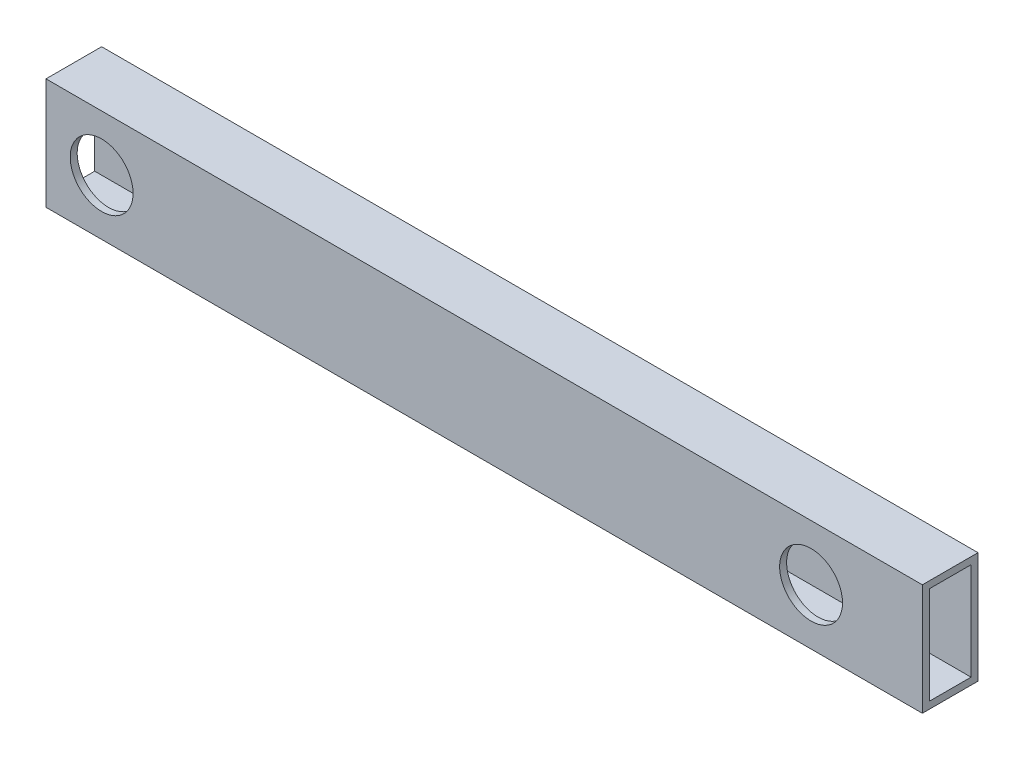
from build123d import *

# Parameters (mm, degrees)
SKETCH1_W           = 25.4
SKETCH1_H           = 50.8
SKETCH1_W_2         = 19.05
SKETCH1_H_2         = 44.45
BOSS_EXTRUDE1_DEPTH = 400.05
SKETCH2_R           = 14.351
CUT_EXTRUDE1_DEPTH  = 25.4


with BuildPart() as part:
    # Sketch1 → Boss-Extrude1 (new body)
    with BuildSketch(Plane(origin=(0, 0, 0), x_dir=(0, 0, -1), z_dir=(1, 0, 0))):
        with Locations((12.7, 25.4)):
            Rectangle(SKETCH1_W, SKETCH1_H)
        with Locations((12.7, 25.4)):
            Rectangle(SKETCH1_W_2, SKETCH1_H_2, mode=Mode.SUBTRACT)
    extrude(amount=BOSS_EXTRUDE1_DEPTH)

    # Sketch2 → Cut-Extrude1 (cut)
    with BuildSketch(Plane.XY):
        with Locations((349.25, 25.4)):
            Circle(SKETCH2_R)
        with Locations((25.4, 25.4)):
            Circle(SKETCH2_R)
    extrude(amount=-CUT_EXTRUDE1_DEPTH, mode=Mode.SUBTRACT)


solid = part.part
